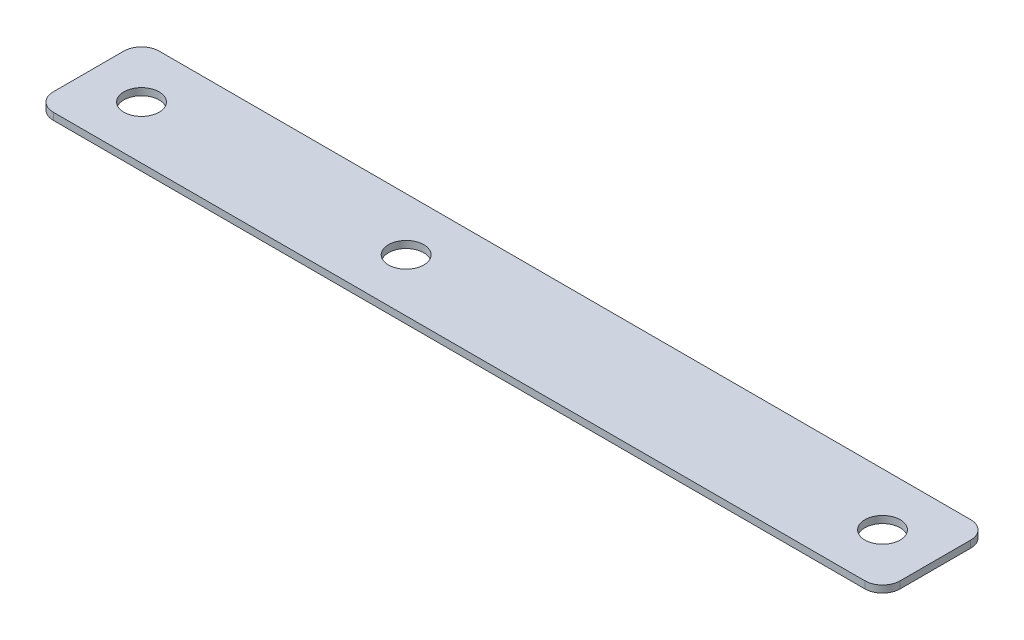
from build123d import *

# Parameters (mm, degrees)
SKETCH1_R           = 6.35
BOSS_EXTRUDE1_DEPTH = 2.54


with BuildPart() as part:
    # Sketch1 → Boss-Extrude1 (new body)
    with BuildSketch(Plane(origin=(0, 0, 0), x_dir=(1, 0, 0), z_dir=(0, 1, 0))):
        with BuildLine():
            Line((6.35, 0), (298.45, 0))
            ThreePointArc((298.45, 0), (302.940128061, 1.859871939), (304.8, 6.35))
            Line((304.8, 6.35), (304.8, 31.75))
            ThreePointArc((304.8, 31.75), (302.940128061, 36.240128061), (298.45, 38.1))
            Line((298.45, 38.1), (6.35, 38.1))
            ThreePointArc((6.35, 38.1), (1.859871939, 36.240128061), (0, 31.75))
            Line((0, 31.75), (0, 6.35))
            ThreePointArc((0, 6.35), (1.859871939, 1.859871939), (6.35, 0))
        make_face()
        with Locations((19.05, 19.05)):
            Circle(SKETCH1_R, mode=Mode.SUBTRACT)
        with Locations((285.75, 19.05)):
            Circle(SKETCH1_R, mode=Mode.SUBTRACT)
        with Locations((114.3, 19.05)):
            Circle(SKETCH1_R, mode=Mode.SUBTRACT)
    extrude(amount=BOSS_EXTRUDE1_DEPTH)


solid = part.part
